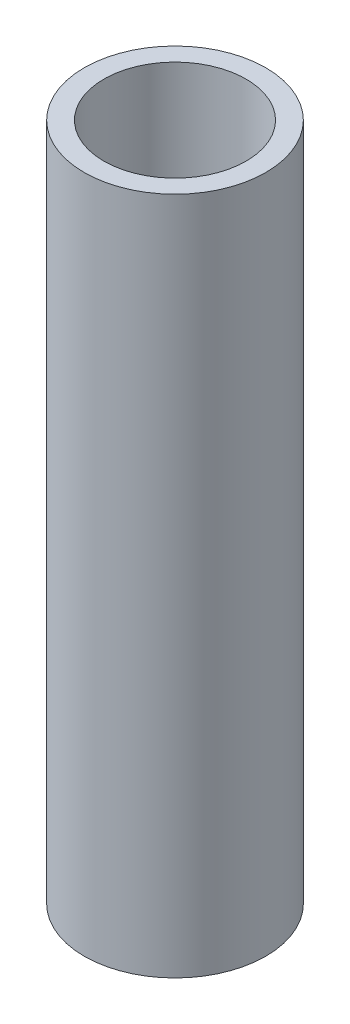
from build123d import *

# Parameters (mm, degrees)
SKETCH1_R           = 13.3731
SKETCH1_R_2         = 10.4775
BOSS_EXTRUDE1_DEPTH = 99.9998


with BuildPart() as part:
    # Sketch1 → Boss-Extrude1 (new body)
    with BuildSketch(Plane(origin=(0, 0, 0), x_dir=(1, 0, 0), z_dir=(0, 1, 0))):
        Circle(SKETCH1_R)
        Circle(SKETCH1_R_2, mode=Mode.SUBTRACT)
    extrude(amount=BOSS_EXTRUDE1_DEPTH)


solid = part.part
